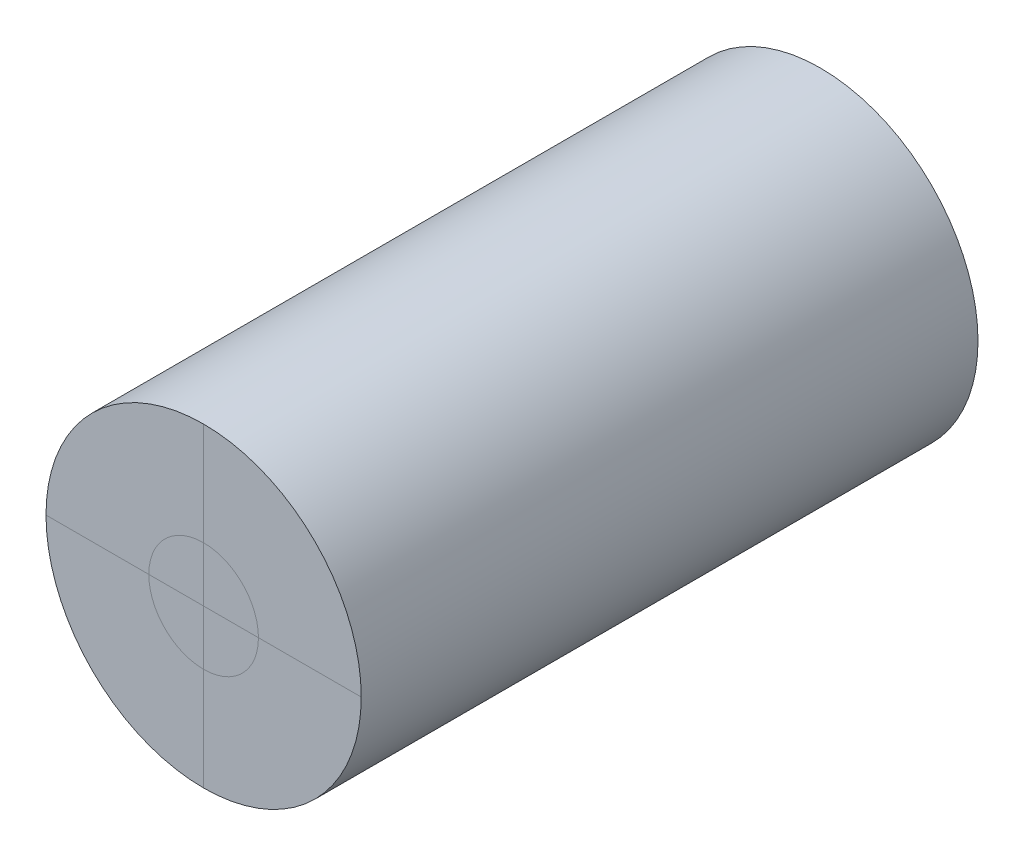
from build123d import *

# Parameters (mm, degrees)
SKETCH1_R           = 14.605
BOSS_EXTRUDE1_DEPTH = 57.15


with BuildPart() as part:
    # Sketch1 → Boss-Extrude1 (new body)
    with BuildSketch(Plane.XY):
        Circle(SKETCH1_R)
    extrude(amount=BOSS_EXTRUDE1_DEPTH)


solid = part.part
